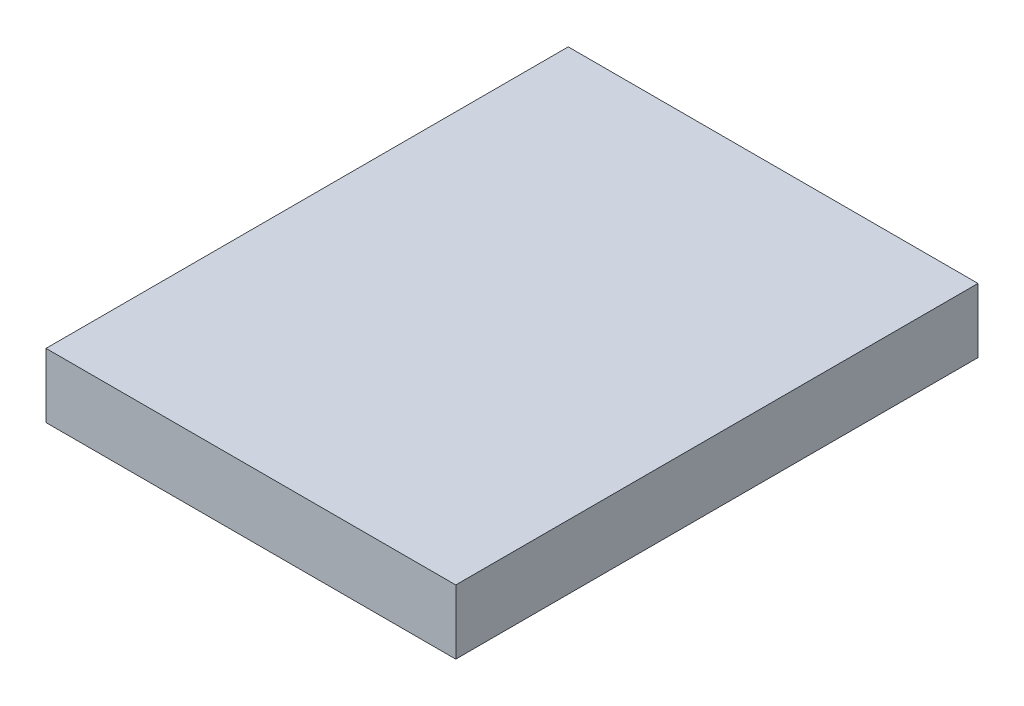
from build123d import *

# Parameters (mm, degrees)
SKETCH1_W           = 51
SKETCH1_H           = 65
BOSS_EXTRUDE1_DEPTH = 8


with BuildPart() as part:
    # Sketch1 → Boss-Extrude1 (new body)
    with BuildSketch(Plane(origin=(0, 0, 0), x_dir=(1, 0, 0), z_dir=(0, 1, 0))):
        Rectangle(SKETCH1_W, SKETCH1_H)
    extrude(amount=BOSS_EXTRUDE1_DEPTH)


solid = part.part
